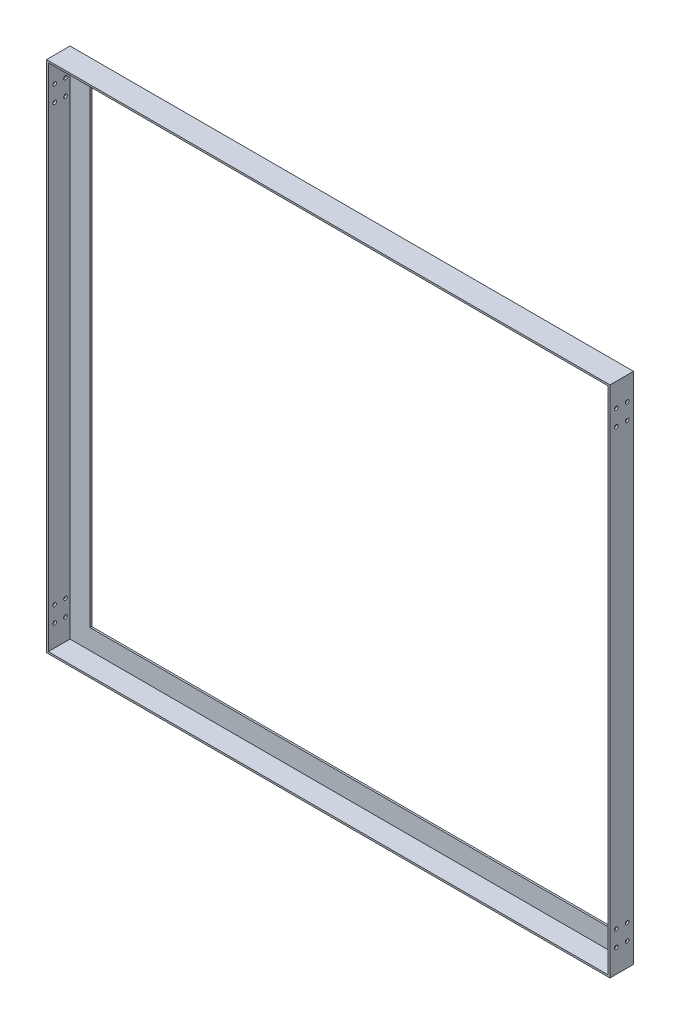
from build123d import *

# Parameters (mm, degrees)
CROQUIS1_W              = 987.3
CROQUIS1_H              = 900
CROQUIS1_W_2            = 911.1
CROQUIS1_H_2            = 823.8
SALIENTE_EXTRUIR1_DEPTH = 3.1
CROQUIS2_W              = 987.3
CROQUIS2_H              = 900
CROQUIS2_W_2            = 981.1
CROQUIS2_H_2            = 893.8
SALIENTE_EXTRUIR2_DEPTH = 38.1
CROQUIS3_R              = 3.175
CORTAR_EXTRUIR1_DEPTH   = 1000


with BuildPart() as part:
    # Croquis1 → Saliente-Extruir1 (new body)
    with BuildSketch(Plane.XY):
        with Locations((-493.65, 450)):
            Rectangle(CROQUIS1_W, CROQUIS1_H)
        with Locations((-493.65, 450)):
            Rectangle(CROQUIS1_W_2, CROQUIS1_H_2, mode=Mode.SUBTRACT)
    extrude(amount=SALIENTE_EXTRUIR1_DEPTH)

    # Croquis2 → Saliente-Extruir2 (add)
    with BuildSketch(Plane.XY.offset(3.1)):
        with Locations((-493.65, 450)):
            Rectangle(CROQUIS2_W, CROQUIS2_H)
        with Locations((-493.65, 450)):
            Rectangle(CROQUIS2_W_2, CROQUIS2_H_2, mode=Mode.SUBTRACT)
    extrude(amount=SALIENTE_EXTRUIR2_DEPTH)

    # Croquis3 → Cortar-Extruir1 (cut)
    with BuildSketch(Plane.ZY.offset(987.3)):
        with Locations((11.075, 859)):
            Circle(CROQUIS3_R)
        with Locations((11.075, 831)):
            Circle(CROQUIS3_R)
        with Locations((30.125, 859)):
            Circle(CROQUIS3_R)
        with Locations((30.125, 831)):
            Circle(CROQUIS3_R)
        with Locations((30.125, 69)):
            Circle(CROQUIS3_R)
        with Locations((11.075, 69)):
            Circle(CROQUIS3_R)
        with Locations((11.075, 41)):
            Circle(CROQUIS3_R)
        with Locations((30.125, 41)):
            Circle(CROQUIS3_R)
    extrude(amount=-CORTAR_EXTRUIR1_DEPTH, mode=Mode.SUBTRACT)


solid = part.part
